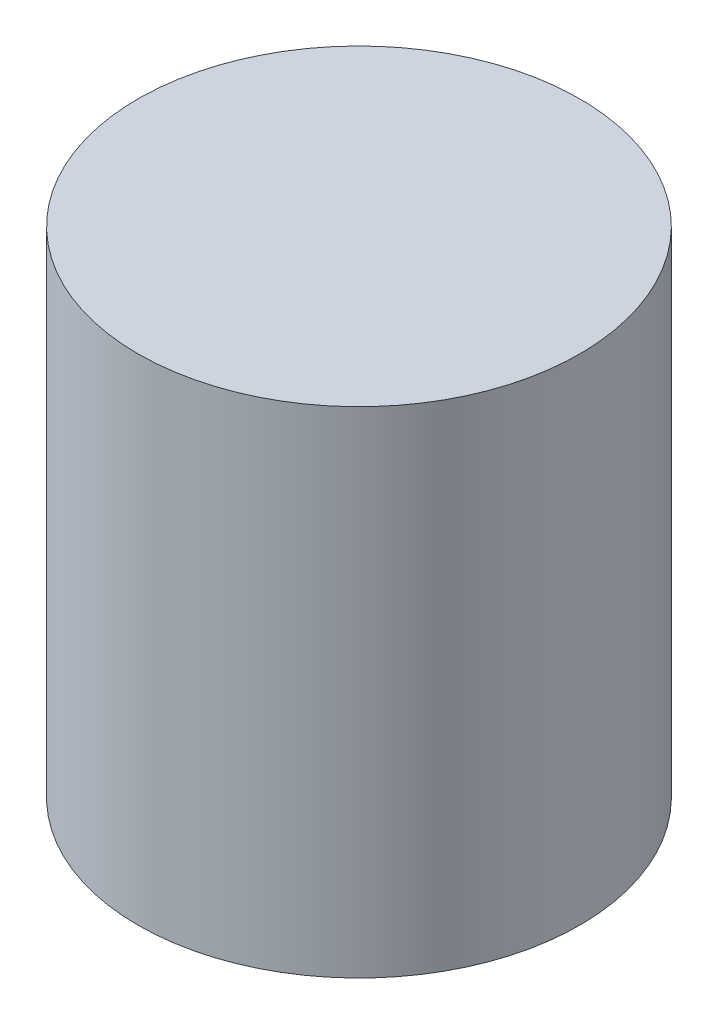
from build123d import *

# Parameters (mm, degrees)
SKETCH1_R           = 6.35
BOSS_EXTRUDE1_DEPTH = 14.224


with BuildPart() as part:
    # Sketch1 → Boss-Extrude1 (new body)
    with BuildSketch(Plane(origin=(0, 0, 0), x_dir=(1, 0, 0), z_dir=(0, 1, 0))):
        Circle(SKETCH1_R)
    extrude(amount=BOSS_EXTRUDE1_DEPTH)


solid = part.part
